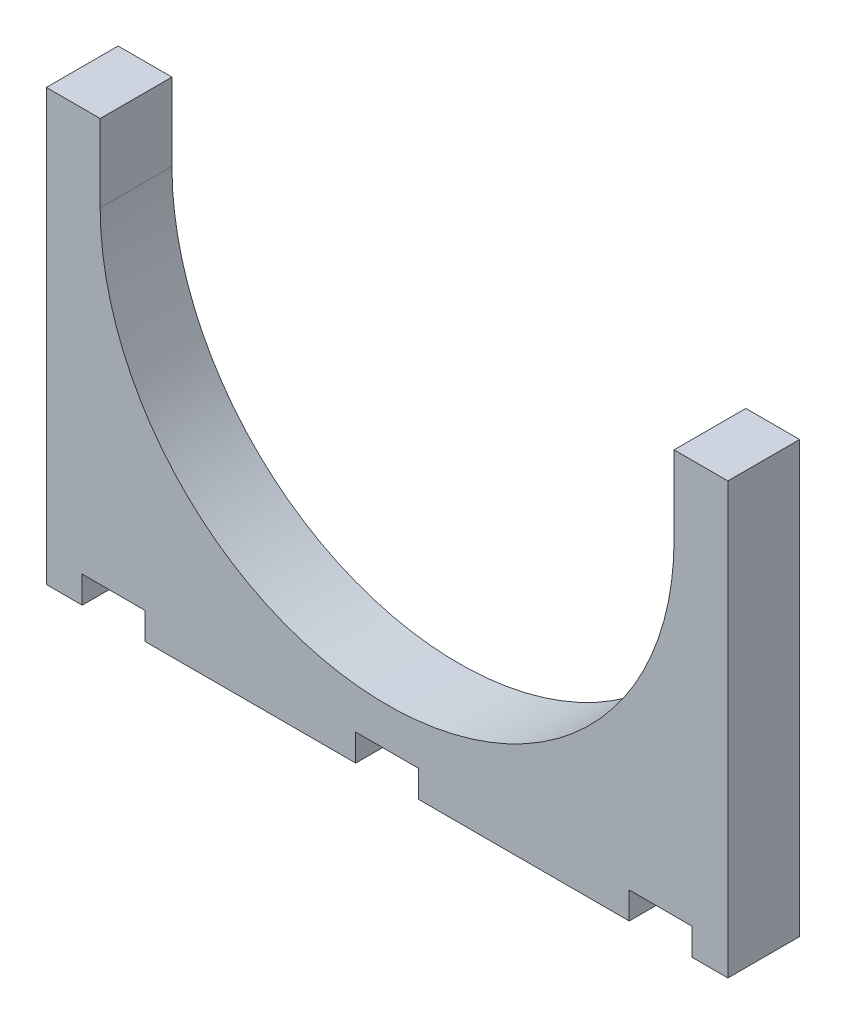
from build123d import *

# Parameters (mm, degrees)
BOSS_EXTRUDE1_DEPTH = 101.6


with BuildPart() as part:
    # Sketch1 → Boss-Extrude1 (new body)
    with BuildSketch(Plane.XY):
        with BuildLine():
            Line((76.2, 500), (76.2, 609.6))
            Line((76.2, 609.6), (0, 609.6))
            Line((0, 609.6), (0, 0))
            Line((0, 0), (50.8, 0))
            Line((50.8, 0), (50.8, 38.1))
            Line((50.8, 38.1), (139.7, 38.1))
            Line((139.7, 38.1), (139.7, 0))
            Line((139.7, 0), (438.1, 0))
            Line((438.1, 0), (438.1, 38.1))
            Line((438.1, 38.1), (527, 38.1))
            Line((527, 38.1), (527, 0))
            Line((527, 0), (825.4, 0))
            Line((825.4, 0), (825.4, 38.1))
            Line((825.4, 38.1), (914.3, 38.1))
            Line((914.3, 38.1), (914.3, 0))
            Line((914.3, 0), (965.1, 0))
            Line((965.1, 0), (965.1, 609.6))
            Line((965.1, 609.6), (888.9, 609.6))
            Line((888.9, 609.6), (888.9, 500))
            ThreePointArc((888.9, 500), (482.55, 93.65), (76.2, 500))
        make_face()
    extrude(amount=BOSS_EXTRUDE1_DEPTH)


solid = part.part
